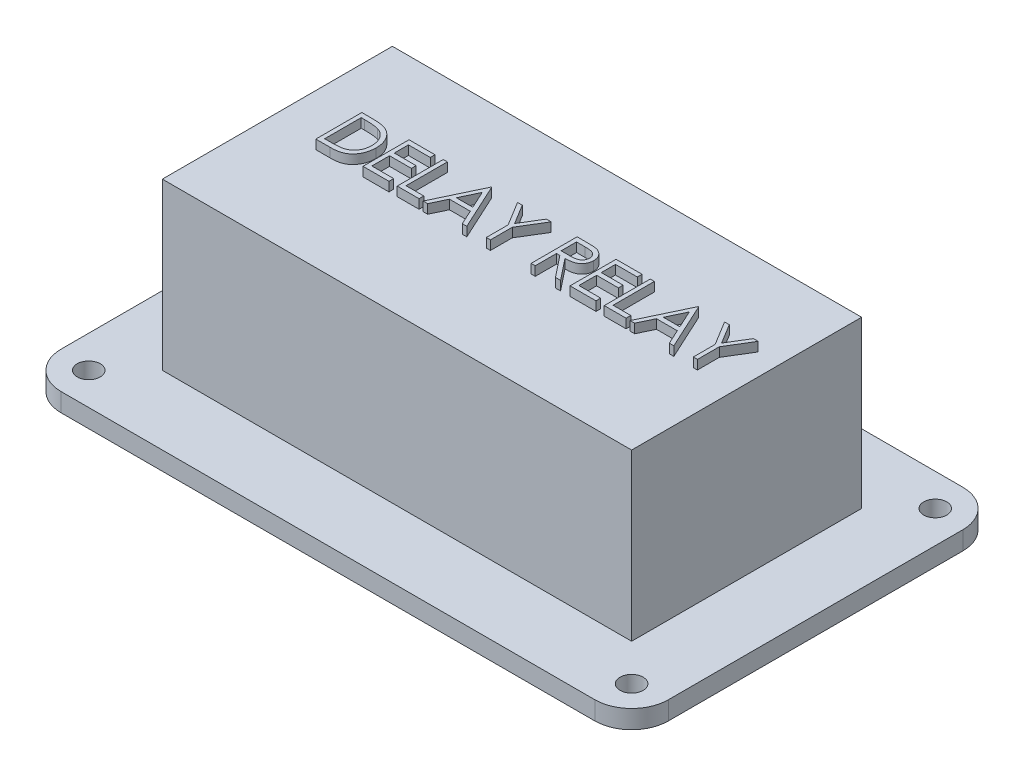
from build123d import *

# Parameters (mm, degrees)
SKETCH1_W                   = 66
SKETCH1_H                   = 40
BOSS_EXTRUDE1_DEPTH         = 2
FILLET1_R                   = 4
TAP_DRILL_FOR_M3X0_5_TAP1_D = 2.5
SKETCH4_W                   = 51
SKETCH4_H                   = 25
BOSS_EXTRUDE2_DEPTH         = 18
BOSS_EXTRUDE3_DEPTH         = 1


with BuildPart() as part:
    # Sketch1 → Boss-Extrude1 (new body)
    with BuildSketch(Plane(origin=(0, 0, 0), x_dir=(1, 0, 0), z_dir=(0, 1, 0))):
        Rectangle(SKETCH1_W, SKETCH1_H)
    extrude(amount=BOSS_EXTRUDE1_DEPTH)

    # Fillet1
    fillet1_edges = [part.edges().sort_by_distance(p)[0] for p in [
        (-33, 1, 20),
        (33, 1, 20),
        (33, 1, -20),
        (-33, 1, -20),
    ]]
    fillet(fillet1_edges, radius=FILLET1_R)

    # Tap Drill for M3x0.5 Tap1 (through all)
    with Locations(Plane(origin=(0, 2, 0), x_dir=(1, 0, 0), z_dir=(0, 1, 0))):
        with Locations((-29.5, 16.5), (29.5, 16.5), (29.5, -16.5), (-29.5, -16.5)):
            Hole(TAP_DRILL_FOR_M3X0_5_TAP1_D / 2)

    # Sketch4 → Boss-Extrude2 (add)
    with BuildSketch(Plane(origin=(0, 2, 0), x_dir=(1, 0, 0), z_dir=(0, 1, 0))):
        Rectangle(SKETCH4_W, SKETCH4_H)
    extrude(amount=BOSS_EXTRUDE2_DEPTH)

    # Sketch5 → Boss-Extrude3 (add)
    with BuildSketch(Plane(origin=(0, 20, 0), x_dir=(1, 0, 0), z_dir=(0, 1, 0))):
        with BuildLine():
            Line((-19.928907286, -1.391695132), (-19.928907286, 3.608304868))
            Line((-19.928907286, 3.608304868), (-18.919291902, 3.608304868))
            add(Edge.make_bspline(
                [(-18.919291902, 3.608304868), (-18.831479061, 3.607672625), (-18.661825111, 3.606451135), (-18.416664472, 3.598706291), (-18.189830525, 3.585005625), (-17.982069298, 3.565049159), (-17.792810424, 3.540544826), (-17.622583841, 3.509829962), (-17.470509351, 3.473561147), (-17.376981579, 3.442639076), (-17.33275344, 3.428016406)],
                knots=[0, 0, 0, 0, 0.000263439, 0.000508962, 0.000735758, 0.000945052, 0.001135011, 0.001308091, 0.001463808, 0.001603505, 0.001603505, 0.001603505, 0.001603505], degree=3))
            add(Edge.make_bspline(
                [(-17.33275344, 3.428016406), (-17.274903813, 3.405972541), (-17.160516395, 3.362384693), (-16.997649077, 3.280161405), (-16.84432713, 3.186999831), (-16.699728352, 3.08277717), (-16.567155742, 2.964542386), (-16.441430176, 2.837317978), (-16.327694856, 2.696477492), (-16.223540147, 2.544941795), (-16.129632062, 2.384496006), (-16.048004694, 2.215445851), (-15.980213275, 2.03864984), (-15.923937237, 1.854599628), (-15.879585155, 1.662890517), (-15.849325252, 1.46329928), (-15.829366695, 1.256614724), (-15.827360908, 1.11636549), (-15.826343184, 1.045203906)],
                knots=[0, 0, 0, 0, 0.000185621, 0.000367033, 0.000546367, 0.00072347, 0.000900892, 0.001078673, 0.001259506, 0.001443149, 0.00162988, 0.001816686, 0.002005668, 0.002197352, 0.002393668, 0.002595391, 0.002802597, 0.003016023, 0.003016023, 0.003016023, 0.003016023], degree=3))
            add(Edge.make_bspline(
                [(-15.826343184, 1.045203906), (-15.827241709, 0.983402137), (-15.829012346, 0.861615296), (-15.844911369, 0.682128302), (-15.868020397, 0.507966057), (-15.903797823, 0.339957914), (-15.947229985, 0.176631889), (-16.002893058, 0.019728683), (-16.066658053, -0.132191045), (-16.141015022, -0.277073153), (-16.222645572, -0.414335114), (-16.310248062, -0.543728726), (-16.403729056, -0.663407614), (-16.50397996, -0.773734202), (-16.609705269, -0.874542172), (-16.72159717, -0.966673622), (-16.839944385, -1.048325843), (-16.964216846, -1.122707426), (-17.098039888, -1.187593649), (-17.243948268, -1.242493663), (-17.402564237, -1.287988827), (-17.573498461, -1.32594725), (-17.757046286, -1.356057682), (-17.953387666, -1.376238243), (-18.162220937, -1.38988529), (-18.305619888, -1.391080137), (-18.37942812, -1.391695132)],
                knots=[0, 0, 0, 0, 0.000185364, 0.000365279, 0.000540216, 0.000712098, 0.000880236, 0.001046858, 0.001211124, 0.001374176, 0.001534957, 0.001689973, 0.001842651, 0.001990135, 0.002136783, 0.002280547, 0.002424472, 0.002567732, 0.002714664, 0.002869994, 0.003034817, 0.003209292, 0.003395032, 0.003592469, 0.003801209, 0.0040226, 0.0040226, 0.0040226, 0.0040226], degree=3))
            Line((-18.37942812, -1.391695132), (-19.928907286, -1.391695132))
        make_face()
        with BuildLine():
            Line((-19.480189338, -0.878874619), (-18.906271068, -0.878874619))
            add(Edge.make_bspline(
                [(-18.906271068, -0.878874619), (-18.823801967, -0.878520196), (-18.665183684, -0.87783851), (-18.437100831, -0.871856791), (-18.228701693, -0.862082595), (-18.039956679, -0.848403912), (-17.870972359, -0.83030589), (-17.721395573, -0.810127458), (-17.591716633, -0.784988243), (-17.513246009, -0.762201158), (-17.476984209, -0.751671094)],
                knots=[0, 0, 0, 0, 0.000247404, 0.000475848, 0.000684422, 0.000873245, 0.001043473, 0.001194187, 0.001325992, 0.001439226, 0.001439226, 0.001439226, 0.001439226], degree=3))
            add(Edge.make_bspline(
                [(-17.476984209, -0.751671094), (-17.431343692, -0.735597439), (-17.34115278, -0.703834049), (-17.211322659, -0.645894533), (-17.090241224, -0.577263004), (-16.97579833, -0.500974042), (-16.869617394, -0.414336896), (-16.770440085, -0.319235483), (-16.678466083, -0.215185805), (-16.594645643, -0.102317002), (-16.51963378, 0.01866842), (-16.454674881, 0.14658104), (-16.397744122, 0.28001934), (-16.353060418, 0.421032424), (-16.318038155, 0.56835965), (-16.293231458, 0.722011383), (-16.277781851, 0.881958929), (-16.275979783, 0.990747678), (-16.275061132, 1.046205509)],
                knots=[0, 0, 0, 0, 0.000145132, 0.000286798, 0.000425819, 0.000562217, 0.000698935, 0.000836363, 0.000974024, 0.001115051, 0.001257637, 0.001400534, 0.001545074, 0.001692364, 0.001843715, 0.001998992, 0.002158954, 0.002325296, 0.002325296, 0.002325296, 0.002325296], degree=3))
            add(Edge.make_bspline(
                [(-16.275061132, 1.046205509), (-16.2757944, 1.104681909), (-16.277234911, 1.219559316), (-16.295341069, 1.388117452), (-16.321800434, 1.550232667), (-16.360062842, 1.705915803), (-16.408821241, 1.855470592), (-16.469670729, 1.998069892), (-16.539194471, 2.135219705), (-16.621913523, 2.263754513), (-16.712507228, 2.385316097), (-16.813047056, 2.496680263), (-16.921935682, 2.598100692), (-17.037985467, 2.691156853), (-17.164467038, 2.772104961), (-17.298400882, 2.844514505), (-17.44175184, 2.905965779), (-17.541484263, 2.938649868), (-17.592168504, 2.955259996)],
                knots=[0, 0, 0, 0, 0.000175352, 0.000344481, 0.00050799, 0.000667836, 0.000824938, 0.000979341, 0.001132543, 0.001285644, 0.001437287, 0.001586929, 0.001735034, 0.001883325, 0.002032514, 0.002184876, 0.002339671, 0.00249963, 0.00249963, 0.00249963, 0.00249963], degree=3))
            add(Edge.make_bspline(
                [(-17.592168504, 2.955259996), (-17.634098713, 2.966854893), (-17.723253842, 2.991508825), (-17.868738791, 3.018402215), (-18.032474719, 3.042122928), (-18.215188577, 3.062205841), (-18.41667209, 3.0766163), (-18.637080216, 3.087432464), (-18.876508223, 3.094727653), (-19.042483271, 3.095225806), (-19.128626838, 3.095484355)],
                knots=[0, 0, 0, 0, 0.000130458, 0.000277391, 0.000443403, 0.000626792, 0.000828674, 0.001049302, 0.001288787, 0.001547209, 0.001547209, 0.001547209, 0.001547209], degree=3))
            Line((-19.128626838, 3.095484355), (-19.480189338, 3.095484355))
            Line((-19.480189338, 3.095484355), (-19.480189338, -0.878874619))
        make_face(mode=Mode.SUBTRACT)
        Polygon((-14.800702158, 3.608304868), (-11.980189338, 3.608304868), (-11.980189338, 3.095484355), (-14.351984209, 3.095484355), (-14.351984209, 1.557022817), (-11.980189338, 1.557022817), (-11.980189338, 1.044202304), (-14.351984209, 1.044202304), (-14.351984209, -0.878874619), (-11.980189338, -0.878874619), (-11.980189338, -1.391695132), (-14.800702158, -1.391695132), align=None)
        Polygon((-11.08275344, 3.608304868), (-10.634035491, 3.608304868), (-10.634035491, -0.878874619), (-8.710958568, -0.878874619), (-8.710958568, -1.391695132), (-11.08275344, -1.391695132), align=None)
        Polygon((-5.826343184, 3.608304868), (-3.518650876, -1.391695132), (-4.006431325, -1.391695132), (-4.745614017, 0.210868971), (-7.01224062, 0.210868971), (-7.772456966, -1.391695132), (-8.26224062, -1.391695132), (-5.890445748, 3.608304868), align=None)
        Polygon((-5.863402479, 2.633745573), (-6.768851197, 0.723689483), (-4.981992222, 0.723689483), align=None, mode=Mode.SUBTRACT)
        Polygon((-3.005830363, 3.608304868), (-2.492008248, 3.608304868), (-1.177905684, 1.459867368), (0.134193675, 3.608304868), (0.648015791, 3.608304868), (-0.954548312, 0.985107753), (-0.954548312, -1.391695132), (-1.403266261, -1.391695132), (-1.403266261, 0.985107753), align=None)
        with BuildLine():
            Line((3.468528611, 3.608304868), (4.469129573, 3.608304868))
            add(Edge.make_bspline(
                [(4.469129573, 3.608304868), (4.535902613, 3.608082602), (4.664114248, 3.607655827), (4.847790349, 3.605276166), (5.014686202, 3.598455658), (5.164714543, 3.592586253), (5.297872622, 3.58188348), (5.414568752, 3.571653984), (5.514265462, 3.55826304), (5.574616679, 3.545826721), (5.601942073, 3.540195894)],
                knots=[0, 0, 0, 0, 0.000200323, 0.000384642, 0.000551017, 0.000701421, 0.00083501, 0.000951717, 0.001052854, 0.001136534, 0.001136534, 0.001136534, 0.001136534], degree=3))
            add(Edge.make_bspline(
                [(5.601942073, 3.540195894), (5.638522964, 3.531157657), (5.710904378, 3.513273995), (5.815118758, 3.475474565), (5.914424935, 3.431732244), (6.008410398, 3.380355501), (6.096604386, 3.320962959), (6.179916258, 3.254579927), (6.258724063, 3.181569633), (6.329840678, 3.100091288), (6.396896466, 3.01461056), (6.453451646, 2.922176621), (6.50220376, 2.825517296), (6.541018785, 2.723649556), (6.572273032, 2.617561311), (6.594310517, 2.506291601), (6.6075265, 2.390347351), (6.608872008, 2.311264624), (6.609554252, 2.271165445)],
                knots=[0, 0, 0, 0, 0.000112973, 0.000223535, 0.000332046, 0.000438282, 0.0005444, 0.000650613, 0.000757615, 0.000866163, 0.000974744, 0.001083144, 0.001190647, 0.001299089, 0.001409706, 0.001522064, 0.001638977, 0.001759236, 0.001759236, 0.001759236, 0.001759236], degree=3))
            add(Edge.make_bspline(
                [(6.609554252, 2.271165445), (6.607455683, 2.204543867), (6.603360832, 2.074547913), (6.565182113, 1.885889511), (6.502644227, 1.709904776), (6.4164681, 1.546815293), (6.306725992, 1.399800085), (6.174833433, 1.270670863), (6.020716846, 1.162613845), (5.877246394, 1.087681267), (5.750511823, 1.039691398), (5.646178519, 1.005925171), (5.532368551, 0.979836649), (5.410172359, 0.956465032), (5.279081423, 0.938819754), (5.139409938, 0.925896048), (4.991058293, 0.917818836), (4.889145336, 0.916615971), (4.836717714, 0.915997176)],
                knots=[0, 0, 0, 0, 0.000199681, 0.000389629, 0.000574641, 0.000758347, 0.00094084, 0.00112287, 0.00130963, 0.001503603, 0.001606651, 0.001715936, 0.001832303, 0.001956651, 0.002089094, 0.002228924, 0.002377378, 0.002534658, 0.002534658, 0.002534658, 0.002534658], degree=3))
            Line((4.836717714, 0.915997176), (6.673656816, -1.391695132))
            Line((6.673656816, -1.391695132), (6.118768996, -1.391695132))
            Line((6.118768996, -1.391695132), (4.281829893, 0.915997176))
            Line((4.281829893, 0.915997176), (3.91724656, 0.915997176))
            Line((3.91724656, 0.915997176), (3.91724656, -1.391695132))
            Line((3.91724656, -1.391695132), (3.468528611, -1.391695132))
            Line((3.468528611, -1.391695132), (3.468528611, 3.608304868))
        make_face()
        with BuildLine():
            Line((3.91724656, 3.095484355), (3.91724656, 1.428817688))
            Line((3.91724656, 1.428817688), (4.832711303, 1.421806471))
            add(Edge.make_bspline(
                [(4.832711303, 1.421806471), (4.875454216, 1.421787561), (4.958302155, 1.421750909), (5.078160247, 1.427456304), (5.189760407, 1.433946758), (5.292675767, 1.443874395), (5.386952303, 1.456668783), (5.472542894, 1.472673046), (5.549587254, 1.49131885), (5.639442309, 1.520178315), (5.73978021, 1.565901199), (5.848825153, 1.63242334), (5.941685636, 1.71609351), (6.020139725, 1.811769876), (6.08318177, 1.916964517), (6.127627562, 2.030416473), (6.15583105, 2.149261613), (6.159157544, 2.230944624), (6.160836303, 2.272167047)],
                knots=[0, 0, 0, 0, 0.000128209, 0.000248506, 0.000359904, 0.000463555, 0.000558601, 0.000645233, 0.000724669, 0.000796254, 0.000928055, 0.001054503, 0.00117794, 0.001301056, 0.001424562, 0.001544156, 0.0016654, 0.001788926, 0.001788926, 0.001788926, 0.001788926], degree=3))
            add(Edge.make_bspline(
                [(6.160836303, 2.272167047), (6.159118988, 2.312376438), (6.155715894, 2.392056779), (6.127931939, 2.50870808), (6.080947109, 2.618803723), (6.017629626, 2.721895844), (5.940487976, 2.815475467), (5.850033958, 2.895542828), (5.748740822, 2.961613492), (5.654067681, 3.003834036), (5.569447378, 3.029719541), (5.495976435, 3.047935489), (5.412960038, 3.062570444), (5.319995097, 3.074296246), (5.217478482, 3.084374737), (5.104891837, 3.091162993), (4.982982151, 3.095182799), (4.898486535, 3.095381497), (4.85474656, 3.095484355)],
                knots=[0, 0, 0, 0, 0.00012053, 0.000238846, 0.000357345, 0.000478278, 0.000600621, 0.000719816, 0.000839275, 0.000962126, 0.001029286, 0.001104593, 0.001189072, 0.001282, 0.00138565, 0.001498049, 0.00162031, 0.001751524, 0.001751524, 0.001751524, 0.001751524], degree=3))
            Line((4.85474656, 3.095484355), (3.91724656, 3.095484355))
        make_face(mode=Mode.SUBTRACT)
        Polygon((7.699297842, 3.608304868), (10.519810662, 3.608304868), (10.519810662, 3.095484355), (8.148015791, 3.095484355), (8.148015791, 1.557022817), (10.519810662, 1.557022817), (10.519810662, 1.044202304), (8.148015791, 1.044202304), (8.148015791, -0.878874619), (10.519810662, -0.878874619), (10.519810662, -1.391695132), (7.699297842, -1.391695132), align=None)
        Polygon((11.41724656, 3.608304868), (11.865964509, 3.608304868), (11.865964509, -0.878874619), (13.789041432, -0.878874619), (13.789041432, -1.391695132), (11.41724656, -1.391695132), align=None)
        Polygon((16.673656816, 3.608304868), (18.981349124, -1.391695132), (18.493568675, -1.391695132), (17.754385983, 0.210868971), (15.48775938, 0.210868971), (14.727543034, -1.391695132), (14.23775938, -1.391695132), (16.609554252, 3.608304868), align=None)
        Polygon((16.636597521, 2.633745573), (15.731148803, 0.723689483), (17.518007778, 0.723689483), align=None, mode=Mode.SUBTRACT)
        Polygon((19.494169637, 3.608304868), (20.007991752, 3.608304868), (21.322094316, 1.459867368), (22.634193675, 3.608304868), (23.148015791, 3.608304868), (21.545451688, 0.985107753), (21.545451688, -1.391695132), (21.096733739, -1.391695132), (21.096733739, 0.985107753), align=None)
    extrude(amount=BOSS_EXTRUDE3_DEPTH)


solid = part.part
